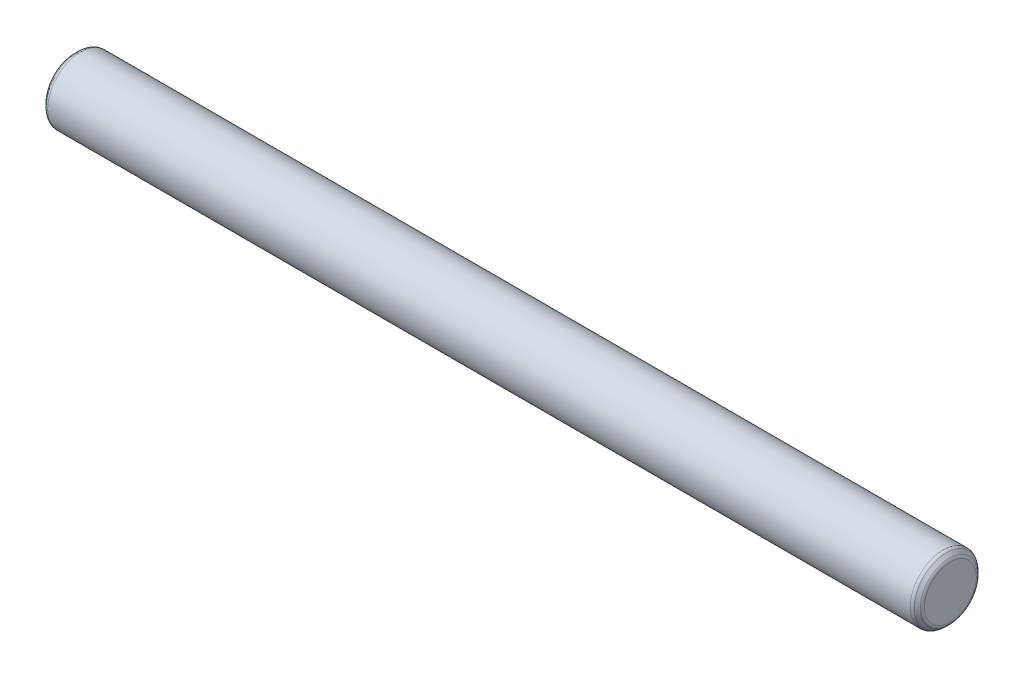
from build123d import *

# Parameters (mm, degrees)
SKETCH1_R           = 3.1115
BOSS_EXTRUDE1_DEPTH = 82.55
CHAMFER1_SIZE       = 0.508
FILLET1_R           = 0.381


with BuildPart() as part:
    # Sketch1 → Boss-Extrude1 (new body)
    with BuildSketch(Plane(origin=(0, 0, 0), x_dir=(0, 0, -1), z_dir=(1, 0, 0))):
        Circle(SKETCH1_R)
    extrude(amount=BOSS_EXTRUDE1_DEPTH)

    # Chamfer1
    chamfer1_edges = [part.edges().sort_by_distance(p)[0] for p in [
        (0, 0, 3.1115),
        (82.55, 0, 3.1115),
    ]]
    chamfer(chamfer1_edges, length=CHAMFER1_SIZE)

    # Fillet1
    fillet1_edges = [part.edges().sort_by_distance(p)[0] for p in [
        (82.55, 0, 2.6035),
        (0.508, 0, 3.1115),
        (82.042, 0, 3.1115),
        (0, 0, 2.6035),
    ]]
    fillet(fillet1_edges, radius=FILLET1_R)


solid = part.part
